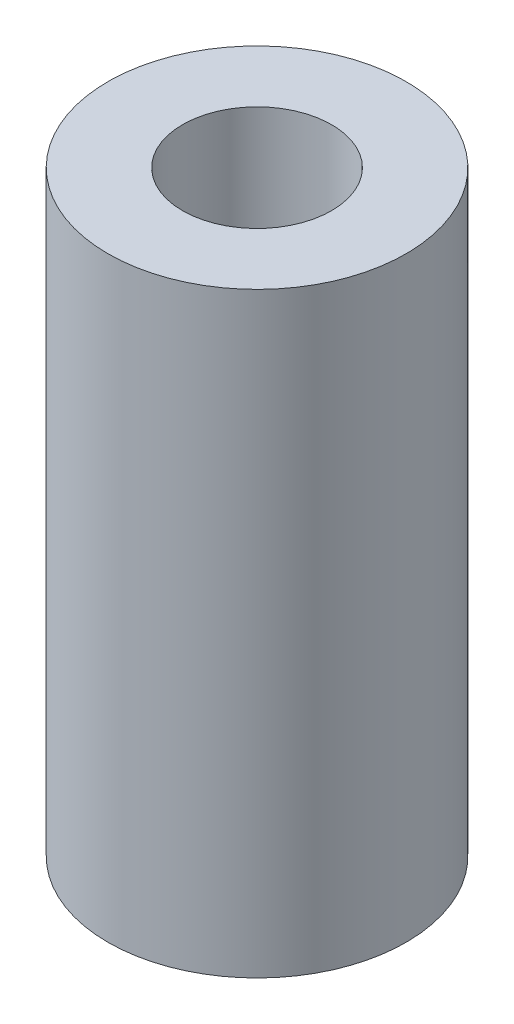
from build123d import *

# Parameters (mm, degrees)
SKETCH1_R           = 6.35
SKETCH1_R_2         = 3.175
BOSS_EXTRUDE1_DEPTH = 25.4


with BuildPart() as part:
    # Sketch1 → Boss-Extrude1 (new body)
    with BuildSketch(Plane(origin=(0, 0, 0), x_dir=(1, 0, 0), z_dir=(0, 1, 0))):
        Circle(SKETCH1_R)
        Circle(SKETCH1_R_2, mode=Mode.SUBTRACT)
    extrude(amount=BOSS_EXTRUDE1_DEPTH)


solid = part.part
